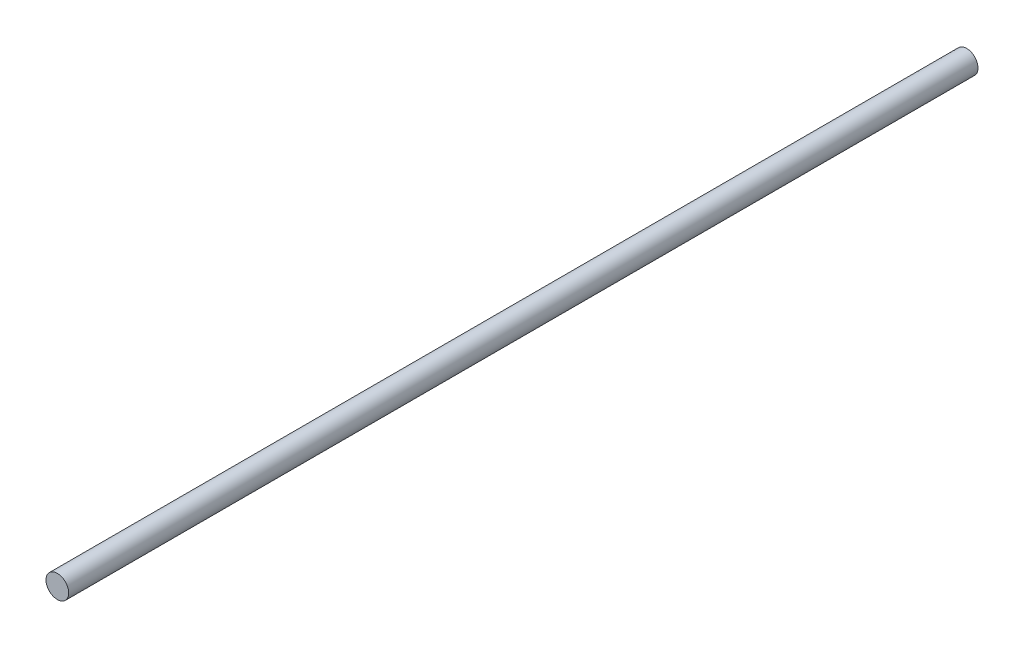
from build123d import *

# Parameters (mm, degrees)
CROQUIS1_R              = 4
SALIENTE_EXTRUIR1_DEPTH = 320


with BuildPart() as part:
    # Croquis1 → Saliente-Extruir1 (new body)
    with BuildSketch(Plane.XY):
        Circle(CROQUIS1_R)
    extrude(amount=SALIENTE_EXTRUIR1_DEPTH)


solid = part.part
